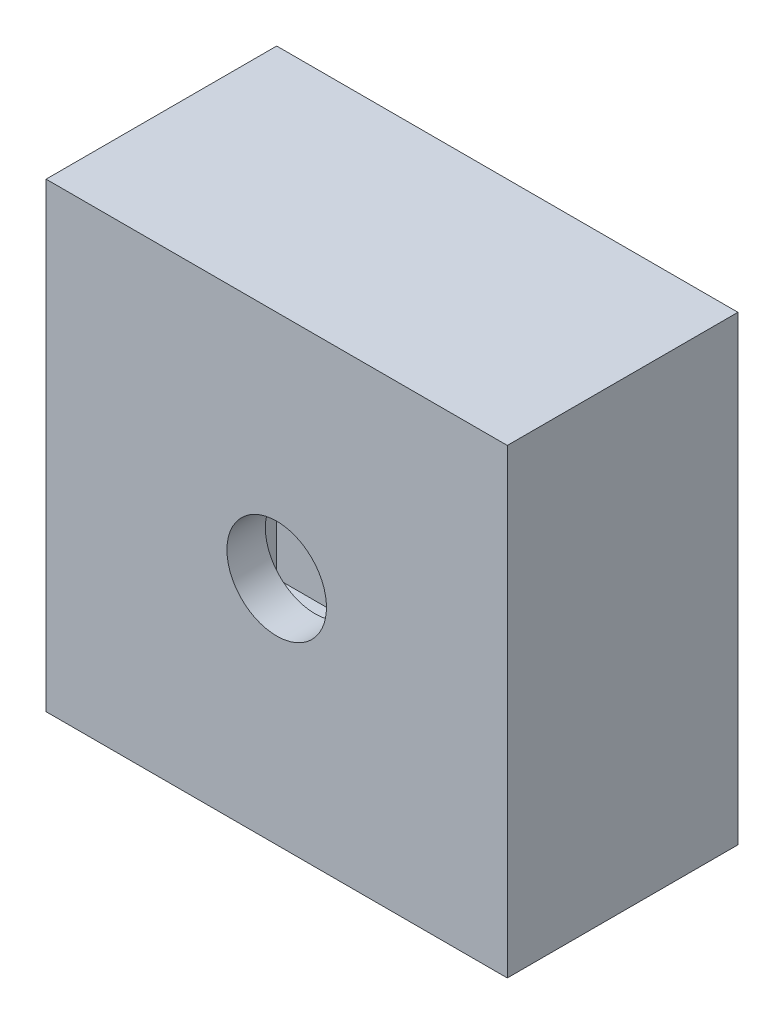
from build123d import *

# Parameters (mm, degrees)
SKETCH2_W           = 1200
SKETCH2_H           = 1200
BOSS_EXTRUDE1_DEPTH = 600
SHELL1_T            = -100
SKETCH4_W           = 1200
SKETCH4_H           = 1200
BOSS_EXTRUDE2_DEPTH = 100
SKETCH5_R           = 129.5
CUT_EXTRUDE2_DEPTH  = 601
SKETCH7_W           = 130
SKETCH7_H           = 130
CUT_EXTRUDE3_DEPTH  = 146
CIRPATTERN1_COUNT   = 4
SKETCH8_R           = 120
CUT_EXTRUDE4_DEPTH  = 100


with BuildPart() as part:
    # Sketch2 → Boss-Extrude1 (new body)
    with BuildSketch(Plane.XY):
        Rectangle(SKETCH2_W, SKETCH2_H)
    extrude(amount=BOSS_EXTRUDE1_DEPTH)

    # Shell1
    shell1_openings = [part.faces().sort_by_distance(p)[0] for p in [
        (0, 0, 600),
    ]]
    offset(amount=SHELL1_T, openings=shell1_openings, kind=Kind.INTERSECTION)

    # Sketch4 → Boss-Extrude2 (add)
    with BuildSketch(Plane.XY.offset(600)):
        Rectangle(SKETCH4_W, SKETCH4_H)
    extrude(amount=-BOSS_EXTRUDE2_DEPTH)

    # Sketch5 → Cut-Extrude2 (cut, through all)
    with BuildSketch(Plane(origin=(0, 0, 0), x_dir=(-1, 0, 0), z_dir=(0, 0, -1))):
        Circle(SKETCH5_R)
    extrude(amount=-CUT_EXTRUDE2_DEPTH, mode=Mode.SUBTRACT)

    # Sketch7 → Cut-Extrude3 (cut)
    with BuildSketch(Plane(origin=(0, 0, 0), x_dir=(-1, 0, 0), z_dir=(0, 0, -1))):
        with Locations((0, 310)):
            Rectangle(SKETCH7_W, SKETCH7_H)
    cut_extrude3 = extrude(amount=-CUT_EXTRUDE3_DEPTH, mode=Mode.SUBTRACT)

    # CirPattern1: Cut-Extrude3 ×4 about axis
    cirpattern1_axis = Axis((0, 0, 0), (0, 0, 1))
    for i in range(1, CIRPATTERN1_COUNT):
        add(cut_extrude3.rotate(cirpattern1_axis, i * 360 / CIRPATTERN1_COUNT), mode=Mode.SUBTRACT)

    # Sketch8 → Cut-Extrude4 (cut)
    with BuildSketch(Plane.XZ.offset(600)):
        with Locations((-344.367385343, 324.291039311)):
            Circle(SKETCH8_R)
    extrude(amount=-CUT_EXTRUDE4_DEPTH, mode=Mode.SUBTRACT)


solid = part.part
